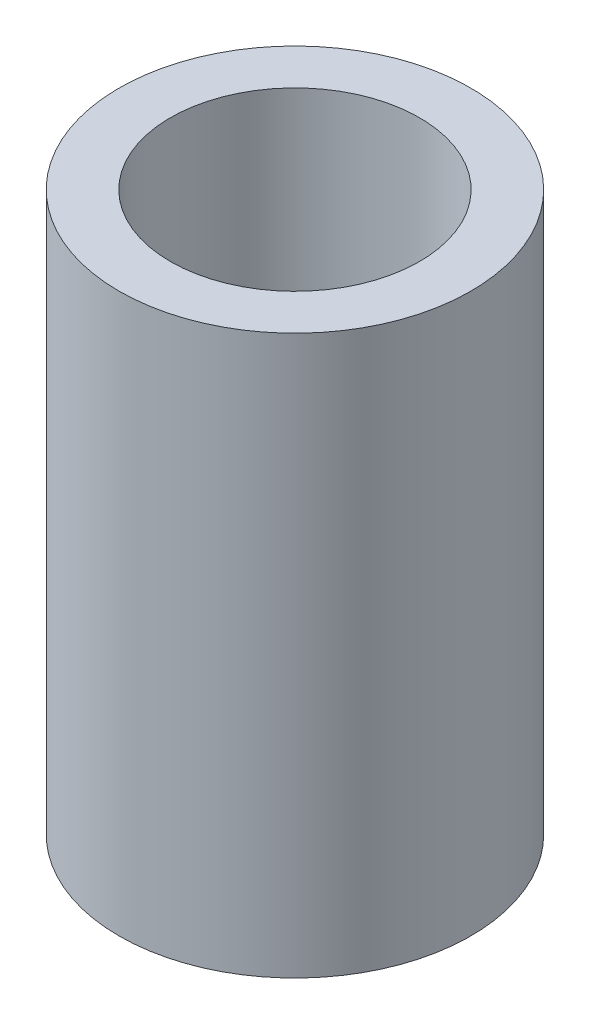
from build123d import *

# Parameters (mm, degrees)
SKETCH1_R           = 6
SKETCH1_R_2         = 4.25
BOSS_EXTRUDE1_DEPTH = 19.05


with BuildPart() as part:
    # Sketch1 → Boss-Extrude1 (new body)
    with BuildSketch(Plane(origin=(0, 0, 0), x_dir=(1, 0, 0), z_dir=(0, 1, 0))):
        Circle(SKETCH1_R)
        Circle(SKETCH1_R_2, mode=Mode.SUBTRACT)
    extrude(amount=BOSS_EXTRUDE1_DEPTH)


solid = part.part
